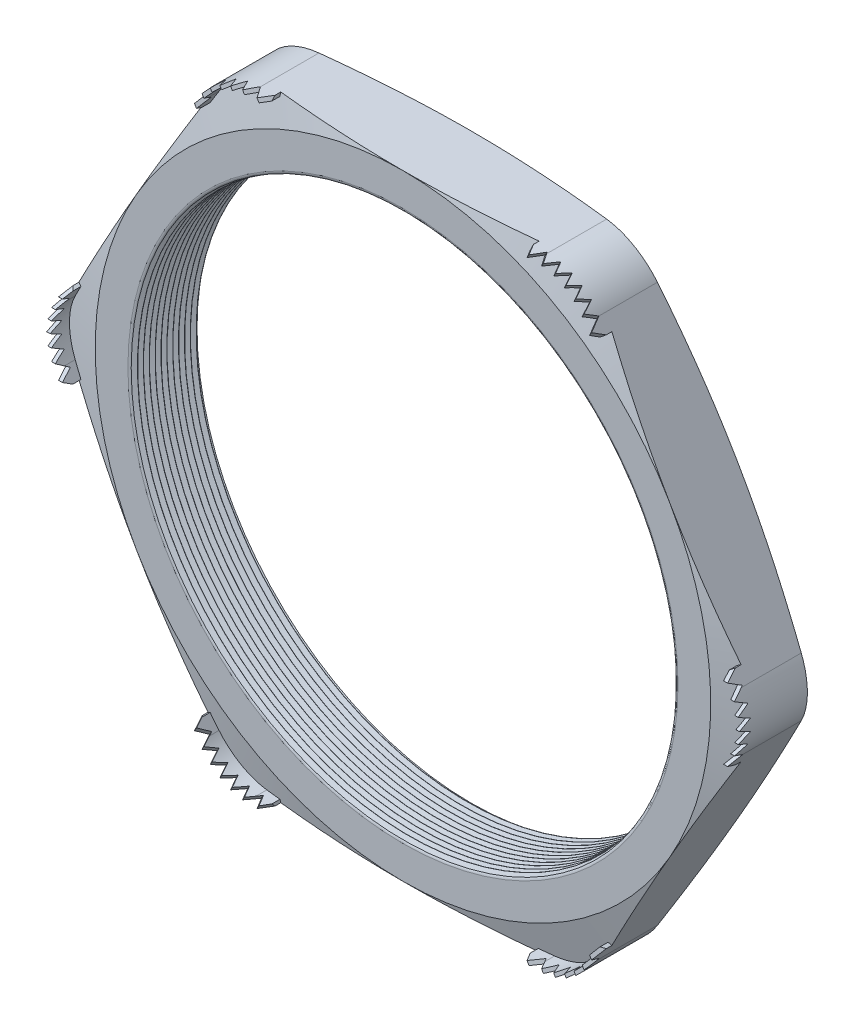
from build123d import *

# Parameters (mm, degrees)
SKETCH1_R          = 14.097
EXTRUDE1_DEPTH     = 3.556
FILLET1_R          = 3.048
FILLET3_R          = 0.2032
LPATTERN1_COUNT    = 12
LPATTERN1_PITCH    = 0.3048
SKETCH4_OUTSIDE_W  = 81.68
SKETCH4_OUTSIDE_H  = 77.672
SKETCH4_OUTSIDE_R  = 16.002
CUT_EXTRUDE1_DEPTH = 4.556
CUT_EXTRUDE1_DRAFT = -75
SKETCH5_OUTSIDE_W  = 81.68
SKETCH5_OUTSIDE_H  = 77.672
SKETCH5_OUTSIDE_R  = 16.002
CUT_EXTRUDE2_DEPTH = 4.5560001
CUT_EXTRUDE2_DRAFT = -75
EXTRUDE2_START     = -0.536968
EXTRUDE2_DEPTH     = 1.933968
CUT_EXTRUDE4_DEPTH = 6.798477147
CIRPATTERN1_COUNT  = 6
CIRPATTERN2_COUNT  = 6


with BuildPart() as part:
    # Sketch1 → Extrude1 (new body)
    with BuildSketch(Plane.XY):
        Polygon((-18.477518015, 0), (-9.238759008, -16.002), (9.238759008, -16.002), (18.477518015, 0), (9.238759008, 16.002), (-9.238759008, 16.002), align=None)
        Circle(SKETCH1_R, mode=Mode.SUBTRACT)
    extrude(amount=EXTRUDE1_DEPTH)

    # Fillet1
    fillet1_edges = [part.edges().sort_by_distance(p)[0] for p in [
        (18.477518015, 0, 1.778),
        (9.238759008, -16.002, 1.778),
        (-9.238759008, -16.002, 1.778),
        (-18.477518015, 0, 1.778),
        (-9.238759008, 16.002, 1.778),
        (9.238759008, 16.002, 1.778),
    ]]
    fillet(fillet1_edges, radius=FILLET1_R)

    # Fillet3
    fillet3_edges = [part.edges().sort_by_distance(p)[0] for p in [
        (-14.097, 0, 0),
        (-14.097, 0, 3.556),
    ]]
    fillet(fillet3_edges, radius=FILLET3_R)

    # Sketch3 → Cut-Revolve1 (revolve, cut)
    with BuildSketch(Plane(origin=(0, 0, 0), x_dir=(1, 0, 0), z_dir=(0, 1, 0))):
        Polygon((-14.097, -3.556), (-14.097, -3.262706063), (-14.351, -3.409353032), align=None)
    cut_revolve1 = revolve(axis=Axis((0, 0, 3.556), (0, 0, -1)), mode=Mode.SUBTRACT)

    # LPattern1: Cut-Revolve1 ×12
    with Locations(*[(0, 0, -i * LPATTERN1_PITCH) for i in range(1, LPATTERN1_COUNT)]):
        add(cut_revolve1, mode=Mode.SUBTRACT)


with BuildPart() as cut_extrude1_tool:
    # Sketch4 outside → Cut-Extrude1 (with draft: the straight prism first)
    with BuildSketch(Plane(origin=(0, 0, 0), x_dir=(-1, 0, 0), z_dir=(0, 0, -1))):
        Rectangle(SKETCH4_OUTSIDE_W, SKETCH4_OUTSIDE_H)
        Circle(SKETCH4_OUTSIDE_R, mode=Mode.SUBTRACT)
    extrude(amount=-CUT_EXTRUDE1_DEPTH)
    # Cut-Extrude1: the draft: its side faces are tilted about the plane it starts from
    cut_extrude1_sides = [cut_extrude1_tool.faces().sort_by_distance(p)[0] for p in [
        (0, -38.836, 2.278),
        (-40.84, 0, 2.278),
        (0, 38.836, 2.278),
        (40.84, 0, 2.278),
        (16.002, 0, 2.278),
    ]]
    draft(cut_extrude1_sides, Plane(origin=(0, 0, 0), x_dir=(-1, 0, 0), z_dir=(0, 0, -1)), CUT_EXTRUDE1_DRAFT)


with BuildPart() as part_1:
    add(part.part)

    # Cut-Extrude1: cut by cut_extrude1_tool
    add(cut_extrude1_tool.part, mode=Mode.SUBTRACT)


with BuildPart() as cut_extrude2_tool:
    # Sketch5 outside → Cut-Extrude2 (with draft: the straight prism first)
    with BuildSketch(Plane.XY.offset(3.556)):
        Rectangle(SKETCH5_OUTSIDE_W, SKETCH5_OUTSIDE_H)
        Circle(SKETCH5_OUTSIDE_R, mode=Mode.SUBTRACT)
    extrude(amount=-CUT_EXTRUDE2_DEPTH)
    # Cut-Extrude2: the draft: its side faces are tilted about the plane it starts from
    cut_extrude2_sides = [cut_extrude2_tool.faces().sort_by_distance(p)[0] for p in [
        (0, -38.836, 1.27799995),
        (40.84, 0, 1.27799995),
        (0, 38.836, 1.27799995),
        (-40.84, 0, 1.27799995),
        (-16.002, 0, 1.27799995),
    ]]
    draft(cut_extrude2_sides, Plane.XY.offset(3.556), CUT_EXTRUDE2_DRAFT)


with BuildPart() as part_2:
    add(part_1.part)

    # Cut-Extrude2: cut by cut_extrude2_tool
    add(cut_extrude2_tool.part, mode=Mode.SUBTRACT)

    # Sketch2 → Extrude2 (add)
    with BuildSketch(Plane.XY.offset(3.556).offset(EXTRUDE2_START)):
        with BuildLine():
            Line((-7.478995387, 16.002), (-6.716995387, 16.002))
            Line((-6.716995387, 16.002), (-6.716995387, 15.8242))
            Line((-6.716995387, 15.8242), (-7.478995387, 15.8242))
            ThreePointArc((-7.478995387, 15.8242), (-8.914095387, 15.439666114), (-9.964661501, 14.3891))
            Line((-9.964661501, 14.3891), (-10.345661501, 13.729188642))
            Line((-10.345661501, 13.729188642), (-10.499640818, 13.818088642))
            Line((-10.499640818, 13.818088642), (-10.118640818, 14.478))
            ThreePointArc((-10.118640818, 14.478), (-9.002995387, 15.593645431), (-7.478995387, 16.002))
        make_face()
    extrude2 = extrude(amount=EXTRUDE2_DEPTH)

    # Sketch7 → Cut-Extrude4 (cut, through all)
    with BuildSketch(Plane(origin=(-8.531328444, 14.776694321, 0), x_dir=(0.866025404, 0.5, 0), z_dir=(0.5, -0.866025404, 0))):
        Polygon((-2.183911358, 3.48615), (-1.879111358, 4.07289), (-1.574311358, 3.48615), (-1.2192, 4.07289), (-0.9144, 3.48615), (-0.6096, 4.07289), (-0.3048, 3.48615), (0, 4.07289), (0.3048, 3.48615), (0.6096, 4.07289), (0.9144, 3.48615), (1.2192, 4.07289), (1.524, 3.48615), (1.879111358, 4.07289), (2.183911358, 3.48615), (2.183911358, 4.953), (-2.183911358, 4.953), align=None)
    cut_extrude4 = extrude(amount=-CUT_EXTRUDE4_DEPTH, mode=Mode.SUBTRACT)

    # CirPattern1: Extrude2 ×6 about axis
    cirpattern1_axis = Axis((0, 0, 0), (0, 0, 1))
    for i in range(1, CIRPATTERN1_COUNT):
        add(extrude2.rotate(cirpattern1_axis, i * 360 / CIRPATTERN1_COUNT))

    # CirPattern2: Cut-Extrude4 ×6 about axis
    cirpattern2_axis = Axis((0, 0, 0), (0, 0, 1))
    for i in range(1, CIRPATTERN2_COUNT):
        add(cut_extrude4.rotate(cirpattern2_axis, i * 360 / CIRPATTERN2_COUNT), mode=Mode.SUBTRACT)


solid = part_2.part
